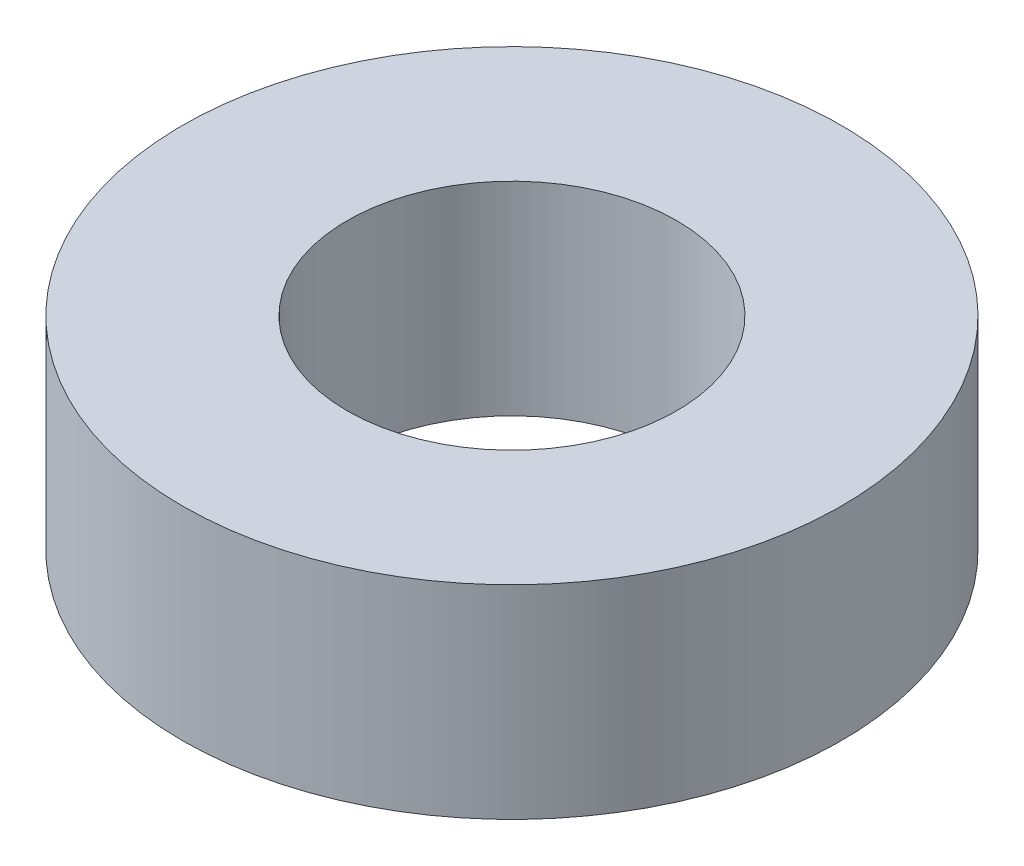
from build123d import *

# Parameters (mm, degrees)
SKETCH1_R           = 3
SKETCH1_R_2         = 1.5
BOSS_EXTRUDE1_DEPTH = 1.85


with BuildPart() as part:
    # Sketch1 → Boss-Extrude1 (new body)
    with BuildSketch(Plane(origin=(0, 0, 0), x_dir=(1, 0, 0), z_dir=(0, 1, 0))):
        Circle(SKETCH1_R)
        Circle(SKETCH1_R_2, mode=Mode.SUBTRACT)
    extrude(amount=BOSS_EXTRUDE1_DEPTH)


solid = part.part
